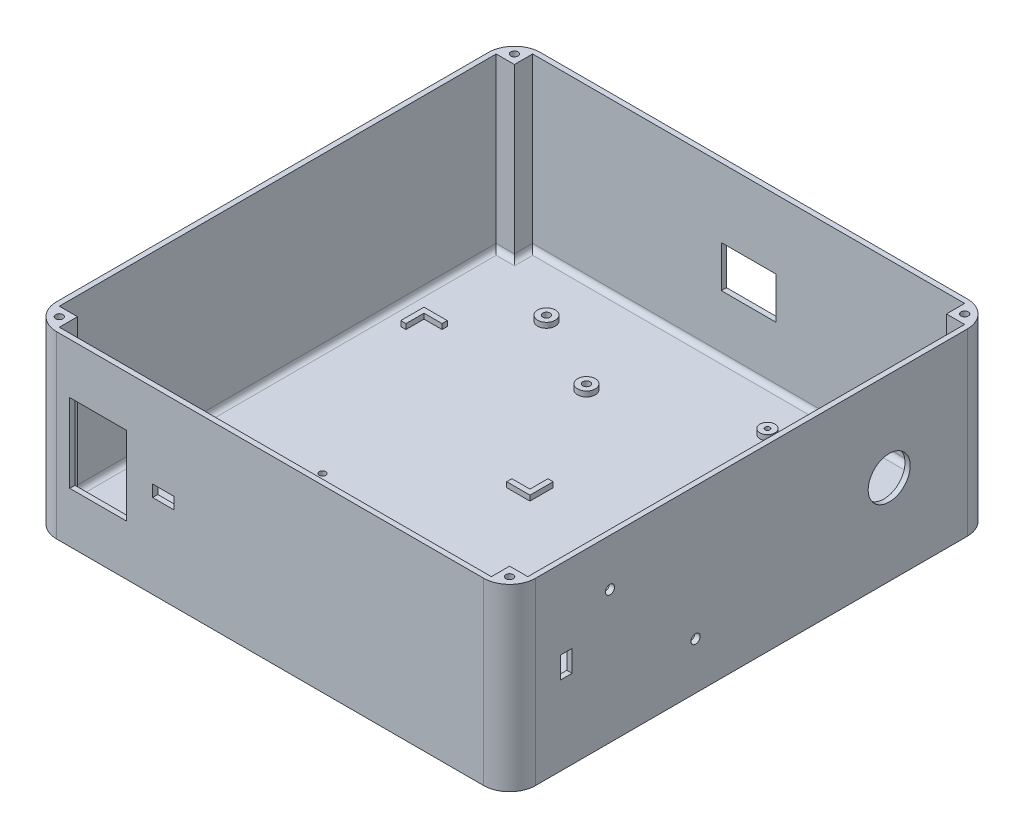
from build123d import *

# Parameters (mm, degrees)
SKETCH1_W           = 184
SKETCH1_H           = 185.84
BOSS_EXTRUDE1_DEPTH = 65
SKETCH2_W           = 184
SKETCH2_H           = 185.84
BOSS_EXTRUDE2_DEPTH = 4
CUT_EXTRUDE1_REACH  = 219.314
SKETCH3_W           = 21.03
SKETCH3_H           = 16.02
CUT_EXTRUDE4_REACH  = 218.137
SKETCH4_R           = 1.75
SKETCH4_R_2         = 8.065
SKETCH4_W           = 4.5
SKETCH4_H           = 8.3
CUT_EXTRUDE3_REACH  = 219.314
SKETCH6_W           = 8.3
SKETCH6_H           = 4.5
SKETCH6_W_2         = 21.85
SKETCH6_H_2         = 30.2
SKETCH8_R           = 3.4
SKETCH8_R_2         = 1.4
SKETCH8_R_3         = 2.9
SKETCH8_R_4         = 0.9
BOSS_EXTRUDE3_DEPTH = 2
SKETCH8_3_R         = 2.14
BOSS_EXTRUDE4_DEPTH = 4
CUT_EXTRUDE5_REACH  = 148.024
SKETCH8_4_R         = 1.25
SKETCH9_R           = 2.25
CUT_EXTRUDE6_DEPTH  = 1.5
SKETCH10_R          = 1.4
CUT_EXTRUDE7_DEPTH  = 4
FILLET1_R           = 10
FILLET2_R           = 2
SKETCH11_R          = 1.4
CUT_EXTRUDE8_DEPTH  = 2.5


with BuildPart() as part:
    # Sketch1 → Boss-Extrude1 (new body)
    with BuildSketch(Plane(origin=(0, 0, 0), x_dir=(1, 0, 0), z_dir=(0, 1, 0))):
        Rectangle(SKETCH1_W, SKETCH1_H)
        Polygon((-90, -83.92), (-90, 83.92), (-83, 83.92), (-83, 90.92), (83, 90.92), (83, 83.92), (90, 83.92), (90, -83.92), (83, -83.92), (83, -90.92), (-83, -90.92), (-83, -83.92), align=None, mode=Mode.SUBTRACT)
    extrude(amount=BOSS_EXTRUDE1_DEPTH)

    # Sketch2 → Boss-Extrude2 (add)
    with BuildSketch(Plane.XZ):
        Rectangle(SKETCH2_W, SKETCH2_H)
    extrude(amount=BOSS_EXTRUDE2_DEPTH)

    # Sketch3 → Cut-Extrude1 (cut, up to next)
    with BuildSketch(Plane(origin=(0, 0, -92.92), x_dir=(-1, 0, 0), z_dir=(0, 0, -1)), mode=Mode.PRIVATE) as cut_extrude1_sk1:
        with Locations((0, 30.5)):
            Rectangle(SKETCH3_W, SKETCH3_H)
    cut_extrude1_tool1 = extrude(cut_extrude1_sk1.sketch, amount=-CUT_EXTRUDE1_REACH, mode=Mode.PRIVATE) & part.part
    add(cut_extrude1_tool1.solids().sort_by_distance((0, 30.5, -92.92))[0], mode=Mode.SUBTRACT)

    # Sketch4 → Cut-Extrude4 (cut, up to next)
    with BuildSketch(Plane(origin=(92, 0, 0), x_dir=(0, 0, -1), z_dir=(1, 0, 0)), mode=Mode.PRIVATE) as cut_extrude4_sk1:
        with Locations((-54.360232663, 46.940232663)):
            Circle(SKETCH4_R)
    cut_extrude4_tool1 = extrude(cut_extrude4_sk1.sketch, amount=-CUT_EXTRUDE4_REACH, mode=Mode.PRIVATE) & part.part
    # Sketch4 → Cut-Extrude4 (cut, up to next)
    with BuildSketch(Plane(origin=(92, 0, 0), x_dir=(0, 0, -1), z_dir=(1, 0, 0)), mode=Mode.PRIVATE) as cut_extrude4_sk2:
        with Locations((-21.479767337, 14.059767337)):
            Circle(SKETCH4_R)
    cut_extrude4_tool2 = extrude(cut_extrude4_sk2.sketch, amount=-CUT_EXTRUDE4_REACH, mode=Mode.PRIVATE) & part.part
    # Sketch4 → Cut-Extrude4 (cut, up to next)
    with BuildSketch(Plane(origin=(92, 0, 0), x_dir=(0, 0, -1), z_dir=(1, 0, 0)), mode=Mode.PRIVATE) as cut_extrude4_sk3:
        with Locations((52.92, 30.5)):
            Circle(SKETCH4_R_2)
    cut_extrude4_tool3 = extrude(cut_extrude4_sk3.sketch, amount=-CUT_EXTRUDE4_REACH, mode=Mode.PRIVATE) & part.part
    # Sketch4 → Cut-Extrude4 (cut, up to next)
    with BuildSketch(Plane(origin=(92, 0, 0), x_dir=(0, 0, -1), z_dir=(1, 0, 0)), mode=Mode.PRIVATE) as cut_extrude4_sk4:
        with Locations((-71.17, 30.5)):
            Rectangle(SKETCH4_W, SKETCH4_H)
    cut_extrude4_tool4 = extrude(cut_extrude4_sk4.sketch, amount=-CUT_EXTRUDE4_REACH, mode=Mode.PRIVATE) & part.part
    add(cut_extrude4_tool1.solids().sort_by_distance((92, 46.940233, 54.360233))[0], mode=Mode.SUBTRACT)
    add(cut_extrude4_tool2.solids().sort_by_distance((92, 14.059767, 21.479767))[0], mode=Mode.SUBTRACT)
    add(cut_extrude4_tool3.solids().sort_by_distance((92, 30.5, -52.92))[0], mode=Mode.SUBTRACT)
    add(cut_extrude4_tool4.solids().sort_by_distance((92, 30.5, 71.17))[0], mode=Mode.SUBTRACT)

    # Sketch6 → Cut-Extrude3 (cut, up to next)
    with BuildSketch(Plane.XY.offset(92.92), mode=Mode.PRIVATE) as cut_extrude3_sk1:
        with Locations((-41, 30.5)):
            Rectangle(SKETCH6_W, SKETCH6_H)
    cut_extrude3_tool1 = extrude(cut_extrude3_sk1.sketch, amount=-CUT_EXTRUDE3_REACH, mode=Mode.PRIVATE) & part.part
    # Sketch6 → Cut-Extrude3 (cut, up to next)
    with BuildSketch(Plane.XY.offset(92.92), mode=Mode.PRIVATE) as cut_extrude3_sk2:
        with Locations((-66.075, 30.5)):
            Rectangle(SKETCH6_W_2, SKETCH6_H_2)
    cut_extrude3_tool2 = extrude(cut_extrude3_sk2.sketch, amount=-CUT_EXTRUDE3_REACH, mode=Mode.PRIVATE) & part.part
    add(cut_extrude3_tool1.solids().sort_by_distance((-41, 30.5, 92.92))[0], mode=Mode.SUBTRACT)
    add(cut_extrude3_tool2.solids().sort_by_distance((-66.075, 30.5, 92.92))[0], mode=Mode.SUBTRACT)

    # Sketch8 → Boss-Extrude3 (add)
    # profile 1 of 6: a face of its own
    with BuildSketch(Plane(origin=(0, 0, 0), x_dir=(1, 0, 0), z_dir=(0, 1, 0))):
        Polygon((0.273995155, 15.554761635), (-1.726004845, 15.554761635), (-1.726004845, 8.62), (-8.660766481, 8.62), (-8.660766481, 6.62), (0.273995155, 6.62), align=None)
    # profile 2 of 6: a face of its own
    with BuildSketch(Plane(origin=(0, 0, 0), x_dir=(1, 0, 0), z_dir=(0, 1, 0))):
        Polygon((-73.69124321, 46.82), (-73.69124321, 48.82), (-82.626004845, 48.82), (-82.626004845, 39.885238365), (-80.626004845, 39.885238365), (-80.626004845, 46.82), align=None)
    # profile 3 of 6: a face of its own
    with BuildSketch(Plane(origin=(0, 0, 0), x_dir=(1, 0, 0), z_dir=(0, 1, 0))):
        with Locations((-56.451004845, 69.7)):
            Circle(SKETCH8_R)
        with Locations((-56.451004845, 69.7)):
            Circle(SKETCH8_R_2, mode=Mode.SUBTRACT)
    # profile 4 of 6: a face of its own
    with BuildSketch(Plane(origin=(0, 0, 0), x_dir=(1, 0, 0), z_dir=(0, 1, 0))):
        with Locations((-25.911004845, 54.52)):
            Circle(SKETCH8_R)
        with Locations((-25.911004845, 54.52)):
            Circle(SKETCH8_R_2, mode=Mode.SUBTRACT)
    # profile 5 of 6: a face of its own
    with BuildSketch(Plane(origin=(0, 0, 0), x_dir=(1, 0, 0), z_dir=(0, 1, 0))):
        with Locations((23.733995155, 74.42)):
            Circle(SKETCH8_R_3)
        with Locations((23.733995155, 74.42)):
            Circle(SKETCH8_R_4, mode=Mode.SUBTRACT)
    # profile 6 of 6: a face of its own
    with BuildSketch(Plane(origin=(0, 0, 0), x_dir=(1, 0, 0), z_dir=(0, 1, 0))):
        with Locations((72.236687484, 26.922654466)):
            Circle(SKETCH8_R_3)
        with Locations((72.236687484, 26.922654466)):
            Circle(SKETCH8_R_4, mode=Mode.SUBTRACT)
    extrude(amount=BOSS_EXTRUDE3_DEPTH)

    # Sketch8_3 → Boss-Extrude4 (add)
    with BuildSketch(Plane(origin=(0, 0, 0), x_dir=(1, 0, 0), z_dir=(0, 1, 0))):
        with BuildLine():
            ThreePointArc((59.523995155, -54.01), (57.383995155, -51.87), (55.243995155, -54.01))
            Line((55.243995155, -54.01), (55.243995155, -56.01))
            ThreePointArc((55.243995155, -56.01), (57.383995155, -58.15), (59.523995155, -56.01))
            Line((59.523995155, -56.01), (59.523995155, -54.01))
        make_face()
        with Locations((57.383995155, -6.52)):
            Circle(SKETCH8_3_R)
    extrude(amount=BOSS_EXTRUDE4_DEPTH)

    # Sketch8_4 → Cut-Extrude5 (cut, up to next)
    with BuildSketch(Plane(origin=(0, 0, 0), x_dir=(1, 0, 0), z_dir=(0, 1, 0)), mode=Mode.PRIVATE) as cut_extrude5_sk1:
        with Locations((-12.616004845, -51.23)):
            Circle(SKETCH8_4_R)
    cut_extrude5_tool1 = extrude(cut_extrude5_sk1.sketch, amount=-CUT_EXTRUDE5_REACH, mode=Mode.PRIVATE) & part.part
    # Sketch8_4 → Cut-Extrude5 (cut, up to next)
    with BuildSketch(Plane(origin=(0, 0, 0), x_dir=(1, 0, 0), z_dir=(0, 1, 0)), mode=Mode.PRIVATE) as cut_extrude5_sk2:
        with Locations((-48.776004845, -24.01)):
            Circle(SKETCH8_4_R)
    cut_extrude5_tool2 = extrude(cut_extrude5_sk2.sketch, amount=-CUT_EXTRUDE5_REACH, mode=Mode.PRIVATE) & part.part
    add(cut_extrude5_tool1.solids().sort_by_distance((-12.616005, 0, 51.23))[0], mode=Mode.SUBTRACT)
    add(cut_extrude5_tool2.solids().sort_by_distance((-48.776005, 0, 24.01))[0], mode=Mode.SUBTRACT)

    # Sketch9 → Cut-Extrude6 (cut)
    with BuildSketch(Plane.XZ.offset(4)):
        with Locations((-12.616004845, 51.23)):
            Circle(SKETCH9_R)
        with Locations((-48.776004845, 24.01)):
            Circle(SKETCH9_R)
    extrude(amount=-CUT_EXTRUDE6_DEPTH, mode=Mode.SUBTRACT)

    # Sketch10 → Cut-Extrude7 (cut)
    with BuildSketch(Plane(origin=(0, 65, 0), x_dir=(1, 0, 0), z_dir=(0, 1, 0))):
        with Locations((-86.5, 87.42)):
            Circle(SKETCH10_R)
        with Locations((86.5, 87.42)):
            Circle(SKETCH10_R)
        with Locations((86.5, -87.42)):
            Circle(SKETCH10_R)
        with Locations((-86.5, -87.42)):
            Circle(SKETCH10_R)
    extrude(amount=-CUT_EXTRUDE7_DEPTH, mode=Mode.SUBTRACT)

    # Fillet1
    fillet1_edges = [part.edges().sort_by_distance(p)[0] for p in [
        (92, 30.5, 92.92),
        (-92, 30.5, -92.92),
        (92, 30.5, -92.92),
        (-92, 30.5, 92.92),
    ]]
    fillet(fillet1_edges, radius=FILLET1_R)

    # Fillet2
    fillet2_edges = [part.edges().sort_by_distance(p)[0] for p in [
        (86.5, 0, 83.92),
        (83, 0, 87.42),
        (83, 0, -87.42),
        (86.5, 0, -83.92),
        (-83, 0, -87.42),
        (-86.5, 0, -83.92),
        (-83, 0, 87.42),
        (-86.5, 0, 83.92),
        (0, 0, 90.92),
        (90, 0, 0),
        (0, 0, -90.92),
        (-90, 0, 0),
    ]]
    fillet(fillet2_edges, radius=FILLET2_R)

    # Sketch11 → Cut-Extrude8 (cut)
    with BuildSketch(Plane.XZ.offset(4)):
        with Locations((25, -25)):
            Circle(SKETCH11_R)
        with Locations((-25, -25)):
            Circle(SKETCH11_R)
        with Locations((25, 25)):
            Circle(SKETCH11_R)
        with Locations((-25, 25)):
            Circle(SKETCH11_R)
    extrude(amount=-CUT_EXTRUDE8_DEPTH, mode=Mode.SUBTRACT)


solid = part.part
